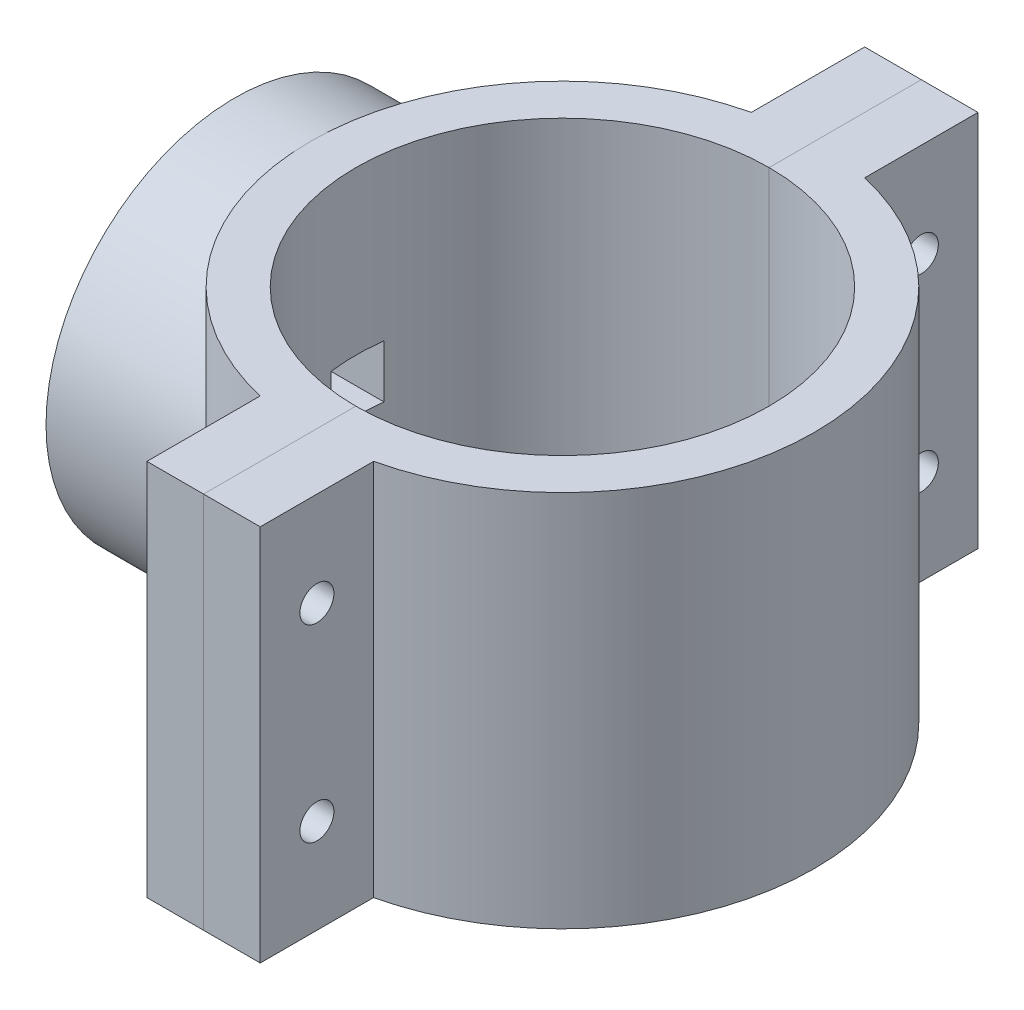
from build123d import *

# Parameters (mm, degrees)
MAIN_BODY_DEPTH          = 50
SKETCH6_R                = 2.25
CUT_EXTRUDE3_DEPTH       = 74.648264845
BOSS_EXTRUDE2_REACH      = 105.144
BOSS_EXTRUDE2_END_RADIUS = 33.35
SKETCH4_R                = 25
SKETCH5_R                = 2.25
CUT_EXTRUDE2_DEPTH       = 104.14424087
CUT_EXTRUDE5_REACH       = 83.456
CUT_EXTRUDE5_END_RADIUS  = 34.35
SKETCH7_W                = 7
SKETCH7_H                = 7


with BuildPart() as part:
    # Sketch2 → main body (new body)
    with BuildSketch(Plane(origin=(0, 0, 0), x_dir=(1, 0, 0), z_dir=(0, 1, 0))):
        with BuildLine():
            Line((0, 27.35), (0, 47.495730489))
            Line((0, 47.495730489), (-7.5, 47.495730489))
            Line((-7.5, 47.495730489), (-7.5, 32.495730489))
            ThreePointArc((-7.5, 32.495730489), (-33.35, 0), (-7.5, -32.495730489))
            Line((-7.5, -32.495730489), (-7.5, -47.495730489))
            Line((-7.5, -47.495730489), (0, -47.495730489))
            Line((0, -47.495730489), (0, -27.35))
            ThreePointArc((0, -27.35), (-27.35, 0), (0, 27.35))
        make_face()
    extrude(amount=MAIN_BODY_DEPTH)

    # Sketch6 → Cut-Extrude3 (cut, through all)
    with BuildSketch(Plane.ZY.offset(7.5)):
        with Locations((-39.995730489, 37.5)):
            Circle(SKETCH6_R)
        with Locations((-39.995730489, 12.5)):
            Circle(SKETCH6_R)
        with Locations((39.995730489, 37.5)):
            Circle(SKETCH6_R)
        with Locations((39.995730489, 12.5)):
            Circle(SKETCH6_R)
    extrude(amount=-CUT_EXTRUDE3_DEPTH, mode=Mode.SUBTRACT)


with BuildPart() as body_2:
    # Mirror2: mirrored copy
    add(part.part.mirror(Plane(origin=(0, 50, -27.35), x_dir=(0, 0, 1), z_dir=(-1, 0, 0))))


with BuildPart() as part_1:
    add(part.part)

    # Boss-Extrude2: up to this cylinder (the profile starts outside it)
    boss_extrude2_end = Plane(origin=(0, 25, 0), z_dir=(0, -1, 0)) * Cylinder(BOSS_EXTRUDE2_END_RADIUS, 277.988, mode=Mode.PRIVATE)
    # Sketch4 → Boss-Extrude2 (add, up to the surface)
    with BuildSketch(Plane.ZY.offset(43.35), mode=Mode.PRIVATE) as boss_extrude2_sk1:
        with Locations((0, 25)):
            Circle(SKETCH4_R)
    boss_extrude2_tool1 = extrude(boss_extrude2_sk1.sketch, amount=-BOSS_EXTRUDE2_REACH, mode=Mode.PRIVATE) - boss_extrude2_end
    add(boss_extrude2_tool1.solids().sort_by_distance((-43.35, 25, 0))[0])

    # Sketch5 → Cut-Extrude2 (cut, through all)
    with BuildSketch(Plane.ZY.offset(43.35)):
        with Locations((0, 25)):
            Circle(SKETCH5_R)
    extrude(amount=-CUT_EXTRUDE2_DEPTH, mode=Mode.SUBTRACT)

    # Cut-Extrude5: up to this cylinder (the profile starts inside it)
    cut_extrude5_end = Plane(origin=(0, 25, 0), z_dir=(0, -1, 0)) * Cylinder(CUT_EXTRUDE5_END_RADIUS, 236.612, mode=Mode.PRIVATE)
    # Sketch7 → Cut-Extrude5 (cut, up to the surface)
    with BuildSketch(Plane(origin=(0, 0, 0), x_dir=(0, 0, -1), z_dir=(1, 0, 0)), mode=Mode.PRIVATE) as cut_extrude5_sk1:
        with Locations((0, 25)):
            Rectangle(SKETCH7_W, SKETCH7_H)
    cut_extrude5_tool1 = extrude(cut_extrude5_sk1.sketch, amount=-CUT_EXTRUDE5_REACH, mode=Mode.PRIVATE) & cut_extrude5_end
    add(cut_extrude5_tool1.solids().sort_by_distance((0, 25, 0))[0], mode=Mode.SUBTRACT)


solid = Compound([body_2.part, part_1.part])
